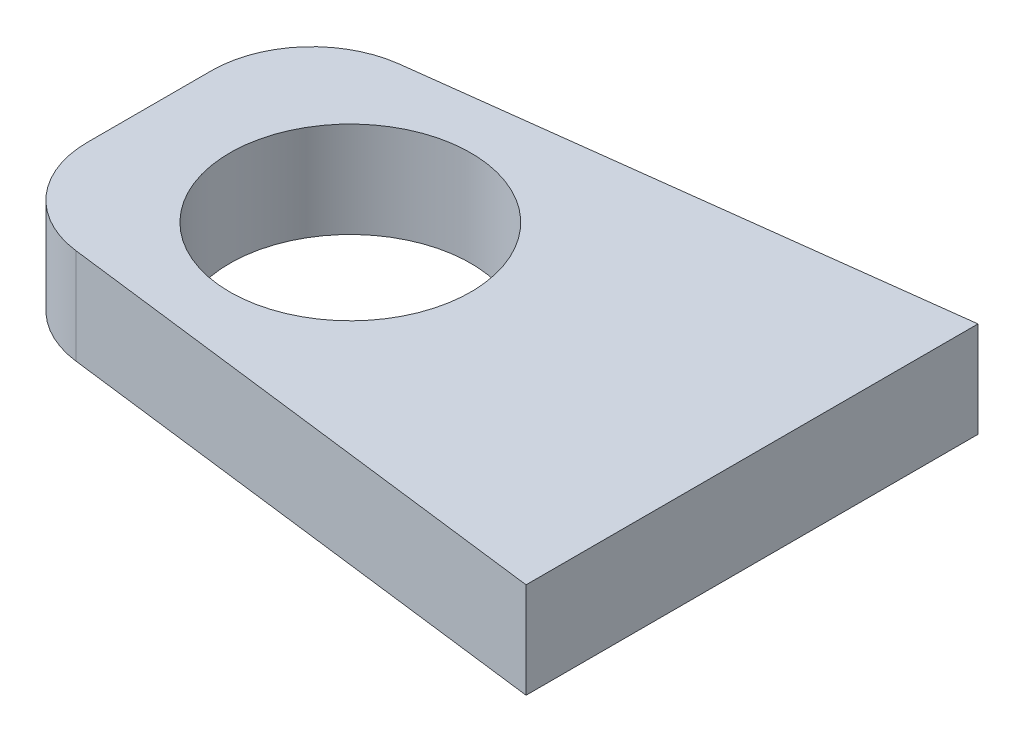
from build123d import *

# Parameters (mm, degrees)
SKETCH1_R           = 6
BOSS_EXTRUDE1_DEPTH = 4.7625
FILLET1_R           = 5


with BuildPart() as part:
    # Sketch1 → Boss-Extrude1 (new body)
    with BuildSketch(Plane(origin=(0, 0, 0), x_dir=(1, 0, 0), z_dir=(0, 1, 0))):
        Polygon((0, -11.25), (0, 11.25), (-30, 7.5), (-30, -7.5), align=None)
        with Locations((-20, 0)):
            Circle(SKETCH1_R, mode=Mode.SUBTRACT)
    extrude(amount=BOSS_EXTRUDE1_DEPTH)

    # Fillet1
    fillet1_edges = [part.edges().sort_by_distance(p)[0] for p in [
        (-30, 2.38125, 7.5),
        (-30, 2.38125, -7.5),
    ]]
    fillet(fillet1_edges, radius=FILLET1_R)


solid = part.part
